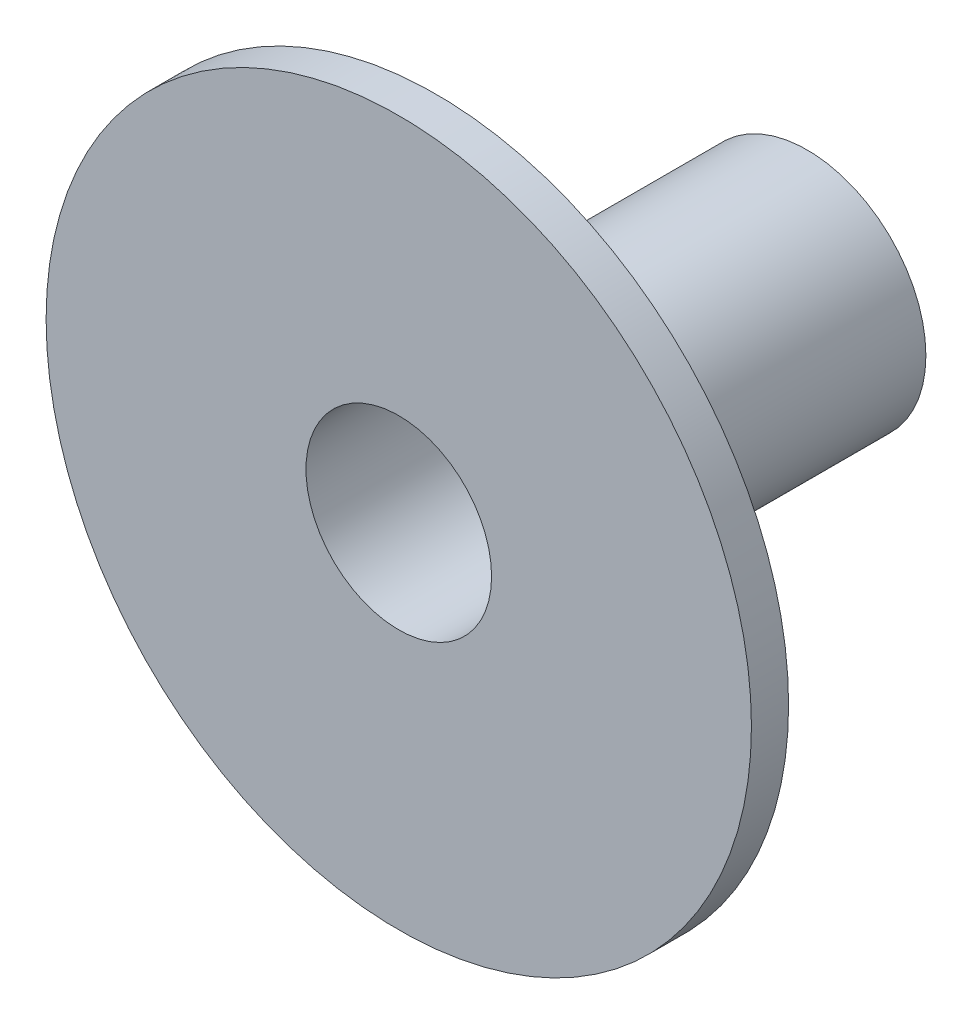
from build123d import *

# Parameters (mm, degrees)
SKETCH2_W           = 1.00076
SKETCH2_H           = 9.4996
SKETCH3_R           = 2.50000008
CUT_EXTRUDE1_DEPTH  = 2.54
SKETCH4_R           = 3.19786
SKETCH4_R_2         = 2.50000008
BOSS_EXTRUDE1_DEPTH = 9.99998


with BuildPart() as part:
    # Sketch2 → Revolve1 (revolve)
    with BuildSketch(Plane(origin=(0, 0, 0), x_dir=(0, 0, -1), z_dir=(1, 0, 0)), mode=Mode.PRIVATE) as revolve1_sk:
        with Locations((0.50038, 4.7498)):
            Rectangle(SKETCH2_W, SKETCH2_H)
    revolve(revolve1_sk.sketch.rotate(Axis((0, 0, -1.00076), (0, 0, 1)), 90), axis=Axis((0, 0, -1.00076), (0, 0, 1)))

    # Sketch3 → Cut-Extrude1 (cut)
    with BuildSketch(Plane.XY):
        Circle(SKETCH3_R)
    extrude(amount=-CUT_EXTRUDE1_DEPTH, mode=Mode.SUBTRACT)

    # Sketch4 → Boss-Extrude1 (add)
    with BuildSketch(Plane(origin=(0, 0, -1.00076), x_dir=(-1, 0, 0), z_dir=(0, 0, -1))):
        with Locations(Location((0, 0, 0), (0, 0, 180))):
            Circle(SKETCH4_R)
        with Locations(Location((0, 0, 0), (0, 0, 180))):
            Circle(SKETCH4_R_2, mode=Mode.SUBTRACT)
    extrude(amount=BOSS_EXTRUDE1_DEPTH)


solid = part.part
